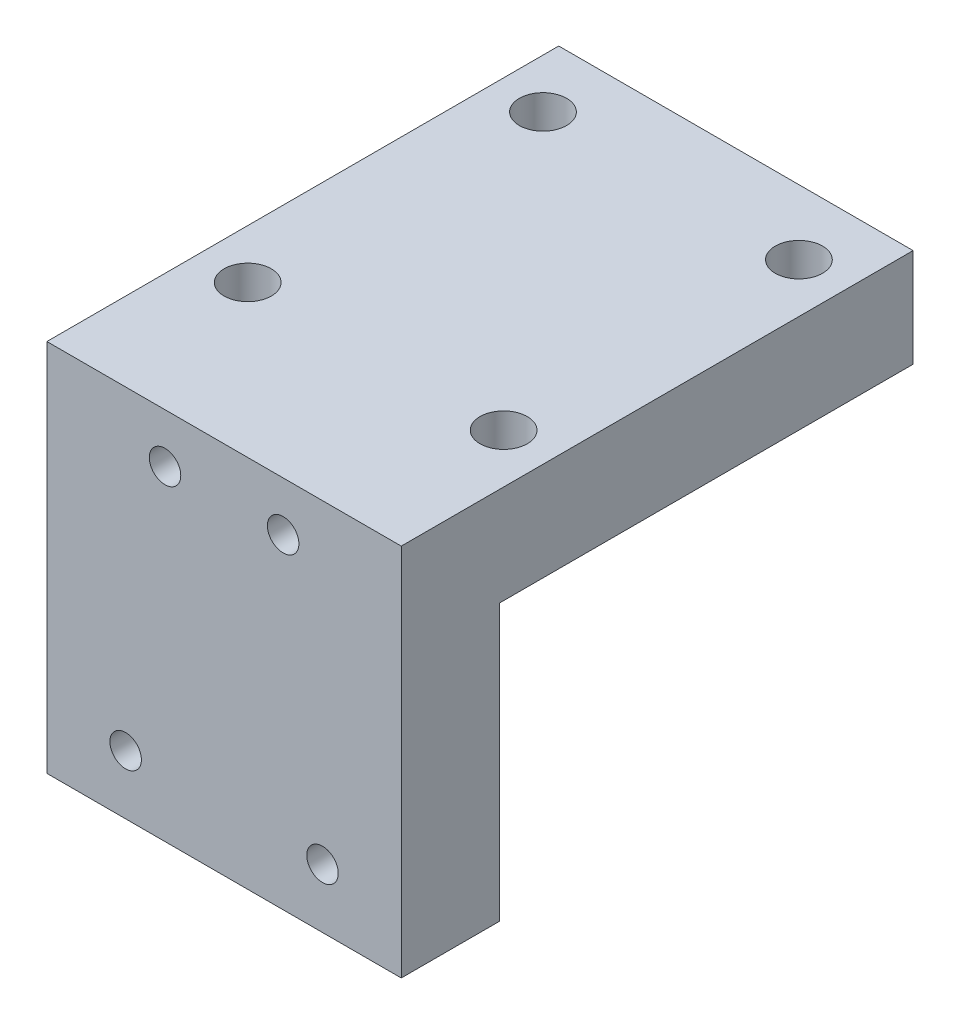
from build123d import *

# Parameters (mm, degrees)
SKETCH1_W                = 18
SKETCH1_H                = 26
BOSS_EXTRUDE1_DEPTH      = 5
SKETCH2_W                = 18
SKETCH2_H                = 5
BOSS_EXTRUDE2_DEPTH      = 14
M2_CLEARANCE_HOLE1_D     = 2.4
M2_CLEARANCE_HOLE1_DEPTH = 10
M2_CLEARANCE_HOLE1_TIP   = 0.721032743
M2_TAPPED_HOLE1_D        = 1.6
M2_TAPPED_HOLE1_DEPTH    = 11.2
M2_TAPPED_HOLE1_TIP      = 0.480688495


with BuildPart() as part:
    # Sketch1 → Boss-Extrude1 (new body)
    with BuildSketch(Plane(origin=(0, 0, 0), x_dir=(1, 0, 0), z_dir=(0, 1, 0))):
        with Locations((9, 13)):
            Rectangle(SKETCH1_W, SKETCH1_H)
    extrude(amount=BOSS_EXTRUDE1_DEPTH)

    # Sketch2 → Boss-Extrude2 (add)
    with BuildSketch(Plane.XZ):
        with Locations((9, -2.5)):
            Rectangle(SKETCH2_W, SKETCH2_H)
    extrude(amount=BOSS_EXTRUDE2_DEPTH)

    # M2 Clearance Hole1
    with Locations(Plane(origin=(2.5, 5, -7.7), x_dir=(0, 0, 1), z_dir=(0, 1, 0))):
        with Locations((0, 0), (-15, 0), (-15, 13), (0, 13)):
            Hole(M2_CLEARANCE_HOLE1_D / 2, depth=M2_CLEARANCE_HOLE1_DEPTH)
            with Locations((0, 0, -(M2_CLEARANCE_HOLE1_DEPTH + M2_CLEARANCE_HOLE1_TIP / 2))):  # 118° drill point
                Cone(0, M2_CLEARANCE_HOLE1_D / 2, M2_CLEARANCE_HOLE1_TIP, mode=Mode.SUBTRACT)

    # M2 Tapped Hole1
    with Locations(Plane.XY):
        with Locations((6, 2.5), (12, 2.5), (4, -11), (14, -11)):
            Hole(M2_TAPPED_HOLE1_D / 2, depth=M2_TAPPED_HOLE1_DEPTH)
            with Locations((0, 0, -(M2_TAPPED_HOLE1_DEPTH + M2_TAPPED_HOLE1_TIP / 2))):  # 118° drill point
                Cone(0, M2_TAPPED_HOLE1_D / 2, M2_TAPPED_HOLE1_TIP, mode=Mode.SUBTRACT)


solid = part.part
